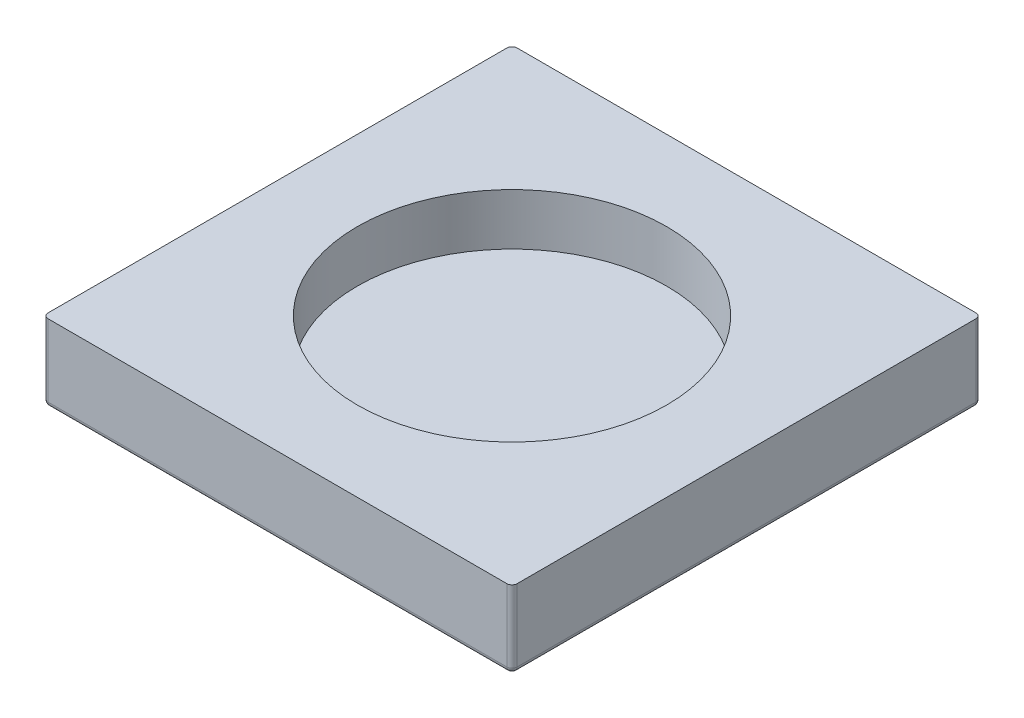
from build123d import *

# Parameters (mm, degrees)
SKETCH1_W           = 45.5
SKETCH1_H           = 45.5
BOSS_EXTRUDE1_DEPTH = 7.5
FILLET1_R           = 0.5
SKETCH2_R           = 15
CUT_EXTRUDE1_DEPTH  = 5


with BuildPart() as part:
    # Sketch1 → Boss-Extrude1 (new body)
    with BuildSketch(Plane(origin=(0, 0, 0), x_dir=(1, 0, 0), z_dir=(0, 1, 0))):
        Rectangle(SKETCH1_W, SKETCH1_H)
    extrude(amount=BOSS_EXTRUDE1_DEPTH)

    # Fillet1
    fillet1_edges = [part.edges().sort_by_distance(p)[0] for p in [
        (0, 0, 22.75),
        (-22.75, 0, 0),
        (0, 0, -22.75),
        (22.75, 0, 0),
        (22.75, 3.75, 22.75),
        (-22.75, 3.75, 22.75),
        (-22.75, 3.75, -22.75),
        (22.75, 3.75, -22.75),
    ]]
    fillet(fillet1_edges, radius=FILLET1_R)

    # Sketch2 → Cut-Extrude1 (cut)
    with BuildSketch(Plane(origin=(0, 7.5, 0), x_dir=(1, 0, 0), z_dir=(0, 1, 0))):
        Circle(SKETCH2_R)
    extrude(amount=-CUT_EXTRUDE1_DEPTH, mode=Mode.SUBTRACT)


solid = part.part
